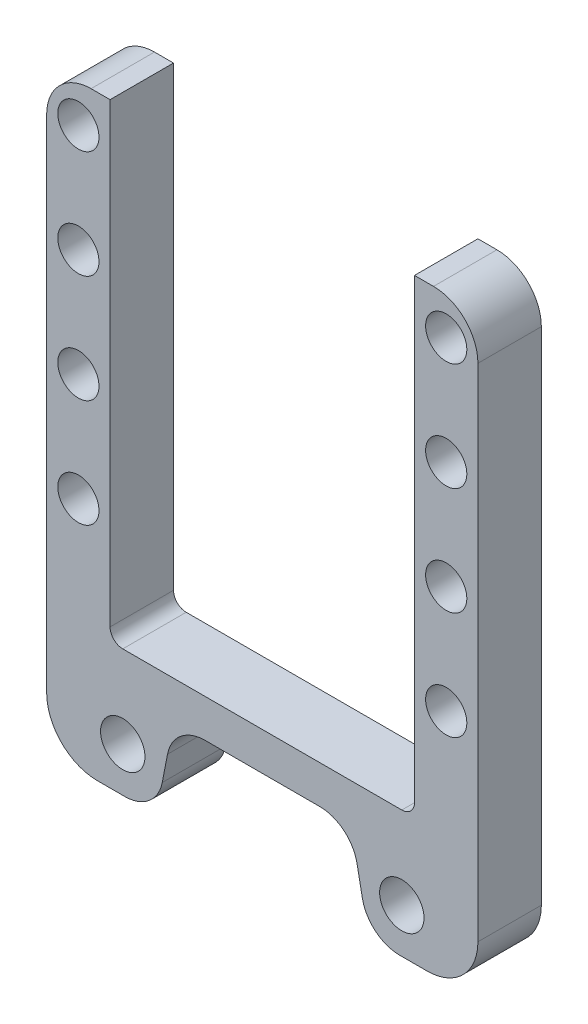
from build123d import *

# Parameters (mm, degrees)
ESQUISSE1_R        = 3.25
ESQUISSE1_R_2      = 3.5
BOSS_EXTRU_1_DEPTH = 10
CONG_1_R           = 6
CONG_2_R           = 8
CONG_3_R           = 7
CONG_4_R           = 2


with BuildPart() as part:
    # Esquisse1 → Boss.-Extru.1 (new body)
    with BuildSketch(Plane.XY):
        Polygon((24, 110), (24, 36), (0, 36), (0, 30), (14, 30), (16.721324328, 16), (34, 16), (34, 110), align=None)
        with Locations((29, 104)):
            Circle(ESQUISSE1_R, mode=Mode.SUBTRACT)
        with Locations((22, 23)):
            Circle(ESQUISSE1_R_2, mode=Mode.SUBTRACT)
        with Locations((29, 87)):
            Circle(ESQUISSE1_R, mode=Mode.SUBTRACT)
        with Locations((29, 70)):
            Circle(ESQUISSE1_R, mode=Mode.SUBTRACT)
        with Locations((29, 53)):
            Circle(ESQUISSE1_R, mode=Mode.SUBTRACT)
    boss_extru_1 = extrude(amount=BOSS_EXTRU_1_DEPTH)

    # Symétrie2: Boss.-Extru.1 across plane
    add(boss_extru_1.mirror(Plane(origin=(0, 36, 10), x_dir=(0, 0, 1), z_dir=(1, 0, 0))))

    # Congé1
    cong_1_edges = [part.edges().sort_by_distance(p)[0] for p in [
        (16.721324328, 16, 5),
        (14, 30, 5),
        (-14, 30, 5),
        (-16.721324328, 16, 5),
    ]]
    fillet(cong_1_edges, radius=CONG_1_R)

    # Congé2
    cong_2_edges = [part.edges().sort_by_distance(p)[0] for p in [
        (34, 16, 5),
        (-34, 16, 5),
    ]]
    fillet(cong_2_edges, radius=CONG_2_R)

    # Congé3
    cong_3_edges = [part.edges().sort_by_distance(p)[0] for p in [
        (34, 110, 5),
        (-34, 110, 5),
    ]]
    fillet(cong_3_edges, radius=CONG_3_R)

    # Congé4
    cong_4_edges = [part.edges().sort_by_distance(p)[0] for p in [
        (24, 36, 5),
        (-24, 36, 5),
    ]]
    fillet(cong_4_edges, radius=CONG_4_R)


solid = part.part
